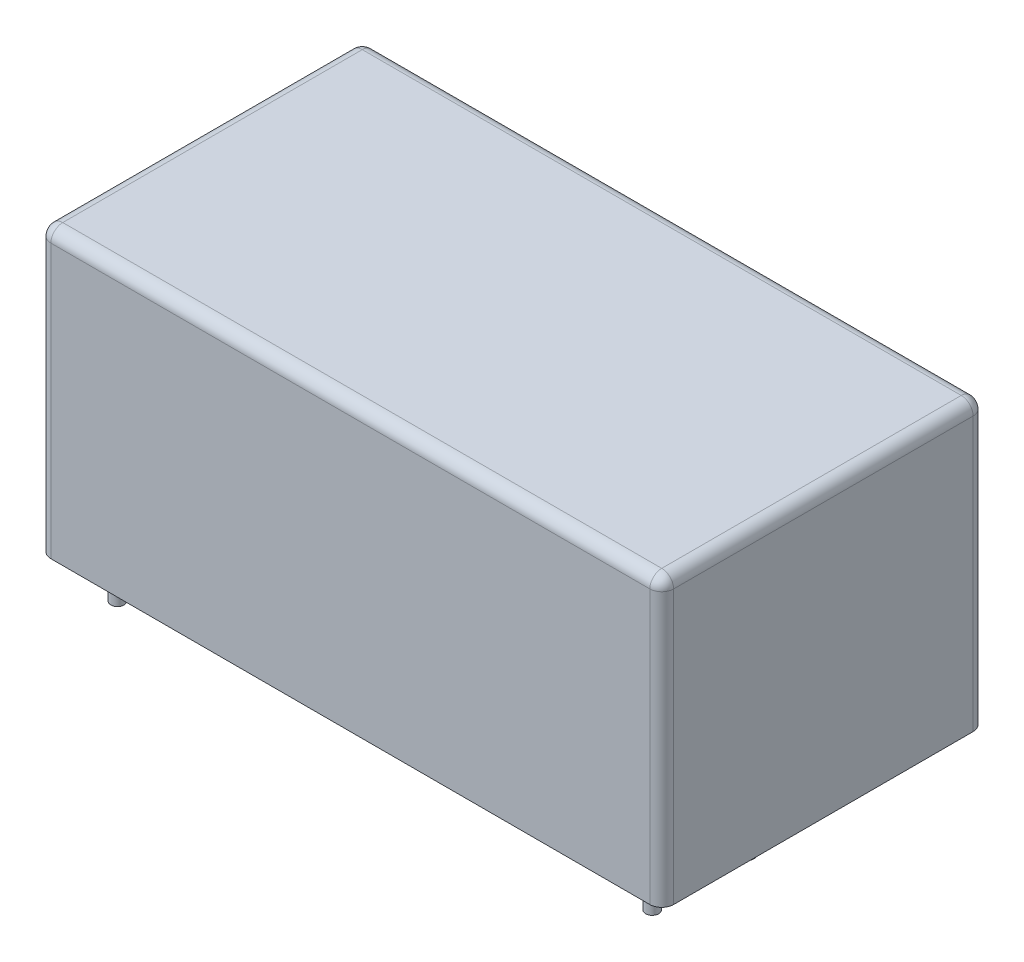
from build123d import *

# Parameters (mm, degrees)
EXTRUDE_1_DEPTH = 24
FILLET_1_R      = 1
SKETCH_870_R    = 0.55
EXTRUDE_2_DEPTH = 3.5


with BuildPart() as part:
    # Эскиз1 → Бобышка-Вытянуть1 (new body)
    with BuildSketch(Plane(origin=(0, 0, 0), x_dir=(1, 0, 0), z_dir=(0, 1, 0))):
        with BuildLine():
            Line((-25.2, 13.6), (25.2, 13.6))
            ThreePointArc((25.2, 13.6), (25.907106781, 13.307106781), (26.2, 12.6))
            Line((26.2, 12.6), (26.2, -12.6))
            ThreePointArc((26.2, -12.6), (25.907106781, -13.307106781), (25.2, -13.6))
            Line((25.2, -13.6), (-25.2, -13.6))
            ThreePointArc((-25.2, -13.6), (-25.907106781, -13.307106781), (-26.2, -12.6))
            Line((-26.2, -12.6), (-26.2, 12.6))
            ThreePointArc((-26.2, 12.6), (-25.907106781, 13.307106781), (-25.2, 13.6))
        make_face()
    extrude(amount=EXTRUDE_1_DEPTH)

    # Скругление1
    fillet_1_edges = [part.edges().sort_by_distance(p)[0] for p in [
        (-25.907106781, 24, -13.307106781),
        (-26.2, 24, 0),
        (-25.907106781, 24, 13.307106781),
        (0, 24, 13.6),
        (25.907106781, 24, 13.307106781),
        (26.2, 24, 0),
        (25.907106781, 24, -13.307106781),
        (0, 24, -13.6),
    ]]
    fillet(fillet_1_edges, radius=FILLET_1_R)

    # Sketch 870 → Бобышка-Вытянуть2 (add)
    with BuildSketch(Plane.XZ):
        with Locations((-22.8, 10.4)):
            Circle(SKETCH_870_R)
        with Locations((-22.8, -10.4)):
            Circle(SKETCH_870_R)
        with Locations((22.2, 10.4)):
            Circle(SKETCH_870_R)
        with Locations((22.2, 2.4)):
            Circle(SKETCH_870_R)
    extrude(amount=EXTRUDE_2_DEPTH)


solid = part.part
